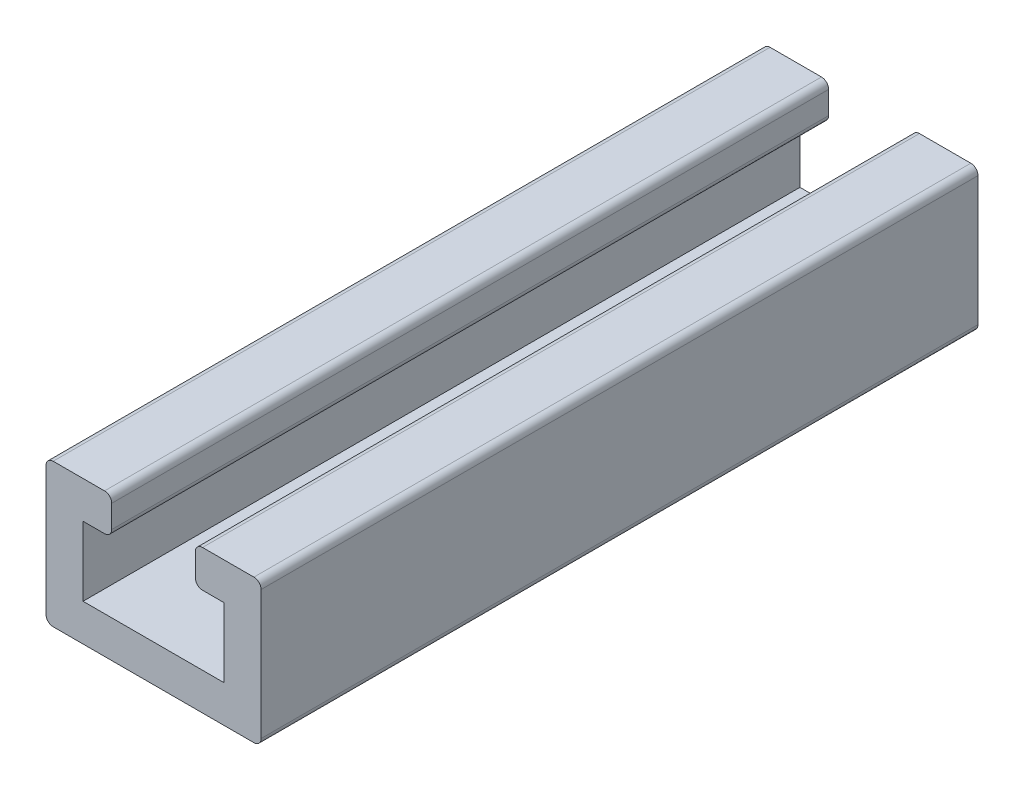
from build123d import *

# Parameters (mm, degrees)
EXTRUDE_1_DEPTH = 30


with BuildPart() as part:
    # 草图1 → 凸台-拉伸1 (new body)
    with BuildSketch(Plane.XY):
        with BuildLine():
            Line((-28.427104886, 7.685760518), (-20.027104886, 7.685760518))
            ThreePointArc((-20.027104886, 7.685760518), (-19.814972852, 7.773628483), (-19.727104886, 7.985760518))
            Line((-19.727104886, 7.985760518), (-19.727104886, 13.385760518))
            ThreePointArc((-19.727104886, 13.385760518), (-19.814972852, 13.597892552), (-20.027104886, 13.685760518))
            Line((-20.027104886, 13.685760518), (-22.177104886, 13.685760518))
            ThreePointArc((-22.177104886, 13.685760518), (-22.389236921, 13.597892552), (-22.477104886, 13.385760518))
            Line((-22.477104886, 13.385760518), (-22.477104886, 12.435760518))
            ThreePointArc((-22.477104886, 12.435760518), (-22.389236921, 12.223628483), (-22.177104886, 12.135760518))
            Line((-22.177104886, 12.135760518), (-21.277104886, 12.135760518))
            Line((-21.277104886, 12.135760518), (-21.277104886, 9.235760518))
            Line((-21.277104886, 9.235760518), (-27.177104886, 9.235760518))
            Line((-27.177104886, 9.235760518), (-27.177104886, 12.135760518))
            Line((-27.177104886, 12.135760518), (-26.277104886, 12.135760518))
            ThreePointArc((-26.277104886, 12.135760518), (-26.064972852, 12.223628483), (-25.977104886, 12.435760518))
            Line((-25.977104886, 12.435760518), (-25.977104886, 13.385760518))
            ThreePointArc((-25.977104886, 13.385760518), (-26.064972852, 13.597892552), (-26.277104886, 13.685760518))
            Line((-26.277104886, 13.685760518), (-28.427104886, 13.685760518))
            ThreePointArc((-28.427104886, 13.685760518), (-28.639236921, 13.597892552), (-28.727104886, 13.385760518))
            Line((-28.727104886, 13.385760518), (-28.727104886, 7.985760518))
            ThreePointArc((-28.727104886, 7.985760518), (-28.639236921, 7.773628483), (-28.427104886, 7.685760518))
        make_face()
    extrude(amount=EXTRUDE_1_DEPTH)


solid = part.part
